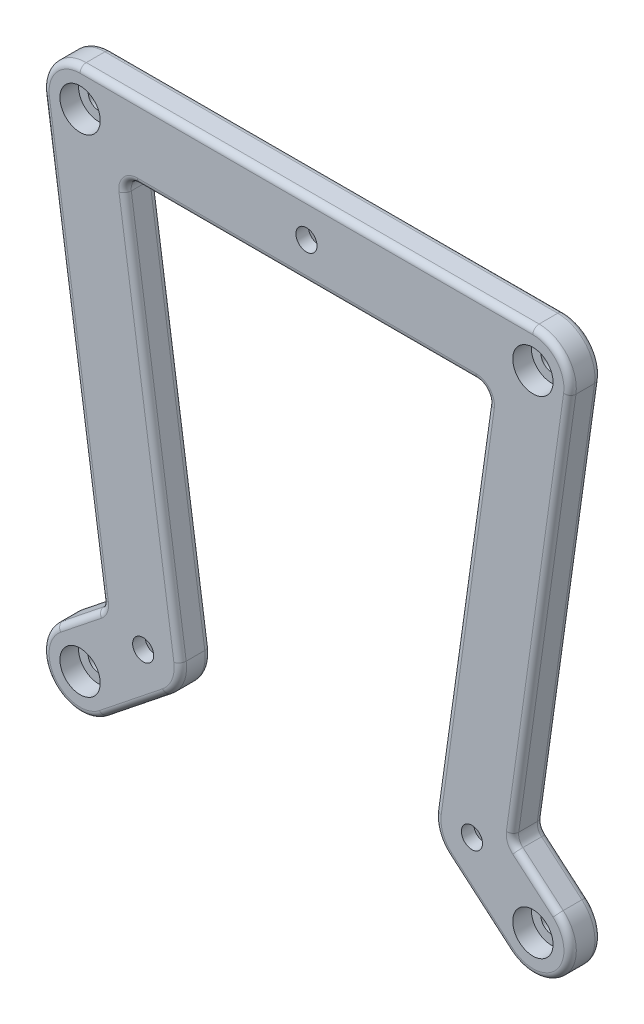
from build123d import *

# Parameters (mm, degrees)
ESQUISSE1_R             = 1.7
BOSS_EXTRU_1_DEPTH      = 5
CONG_1_R                = 2
ESQUISSE2_R             = 3.25
ENL_V_MAT_EXTRU_1_DEPTH = 3
ENL_V_MAT_EXTRU_2_DEPTH = 3
CONG_2_R                = 1


with BuildPart() as part:
    # Esquisse1 → Boss.-Extru.1 (new body)
    with BuildSketch(Plane.XY):
        with BuildLine():
            Line((-22.586329424, -40.018809083), (-32.756329424, -48.138809083))
            ThreePointArc((-32.756329424, -48.138809083), (-41.188809083, -47.193670576), (-40.243670576, -38.761190917))
            Line((-40.243670576, -38.761190917), (-32.759933126, -32.785974782))
            Line((-32.759933126, -32.785974782), (-42.438322378, 34.191904823))
            ThreePointArc((-42.438322378, 34.191904823), (-41.035888615, 38.977558334), (-36.5, 41.05))
            Line((-36.5, 41.05), (36.5, 41.05))
            ThreePointArc((36.5, 41.05), (41.027654088, 38.987048192), (42.441864113, 34.216782821))
            Line((42.441864113, 34.216782821), (33.06867678, -32.625580558))
            Line((33.06867678, -32.625580558), (40.397865204, -38.888569648))
            ThreePointArc((40.397865204, -38.888569648), (41.061430352, -47.347865204), (32.602134796, -48.011430352))
            Line((32.602134796, -48.011430352), (22.772134796, -39.611430352))
            ThreePointArc((22.772134796, -39.611430352), (21.059240359, -37.175882464), (20.728135887, -34.216782821))
            Line((20.728135887, -34.216782821), (29.599925832, 29.05))
            Line((29.599925832, 29.05), (-29.570674099, 29.05))
            Line((-29.570674099, 29.05), (-20.391677622, -34.471904823))
            ThreePointArc((-20.391677622, -34.471904823), (-20.750816941, -37.53742302), (-22.586329424, -40.018809083))
        make_face()
        with Locations((0, 35.05)):
            Circle(ESQUISSE1_R, mode=Mode.SUBTRACT)
        with Locations((-26.33, -35.33)):
            Circle(ESQUISSE1_R, mode=Mode.SUBTRACT)
        with Locations((26.67, -35.05)):
            Circle(ESQUISSE1_R, mode=Mode.SUBTRACT)
        with Locations((-36.5, 35.05)):
            Circle(ESQUISSE1_R, mode=Mode.SUBTRACT)
        with Locations((36.5, 35.05)):
            Circle(ESQUISSE1_R, mode=Mode.SUBTRACT)
        with Locations((-36.5, -43.45)):
            Circle(ESQUISSE1_R, mode=Mode.SUBTRACT)
        with Locations((36.5, -43.45)):
            Circle(ESQUISSE1_R, mode=Mode.SUBTRACT)
    extrude(amount=BOSS_EXTRU_1_DEPTH)

    # Congé1
    cong_1_edges = [part.edges().sort_by_distance(p)[0] for p in [
        (-32.759933126, -32.785974782, 2.5),
        (33.06867678, -32.625580558, 2.5),
        (29.599925832, 29.05, 2.5),
        (-29.570674099, 29.05, 2.5),
    ]]
    fillet(cong_1_edges, radius=CONG_1_R)

    # Esquisse2 → Enlèv. mat.-Extru.1 (cut)
    with BuildSketch(Plane.XY.offset(5)):
        with Locations((-36.5, 35.05)):
            Circle(ESQUISSE2_R)
        with Locations((36.5, 35.05)):
            Circle(ESQUISSE2_R)
        with Locations((36.5, -43.45)):
            Circle(ESQUISSE2_R)
        with Locations((-36.5, -43.45)):
            Circle(ESQUISSE2_R)
    extrude(amount=-ENL_V_MAT_EXTRU_1_DEPTH, mode=Mode.SUBTRACT)

    # Esquisse3 → Enlèv. mat.-Extru.2 (cut)
    with BuildSketch(Plane(origin=(0, 0, 0), x_dir=(-1, 0, 0), z_dir=(0, 0, -1))):
        Polygon((-1.645448267, 37.9), (1.645448267, 37.9), (3.290896534, 35.05), (1.645448267, 32.2), (-1.645448267, 32.2), (-3.290896534, 35.05), align=None)
        Polygon((-28.315448267, -32.2), (-25.024551733, -32.2), (-23.379103466, -35.05), (-25.024551733, -37.9), (-28.315448267, -37.9), (-29.960896534, -35.05), align=None)
        Polygon((24.684551733, -32.48), (27.975448267, -32.48), (29.620896534, -35.33), (27.975448267, -38.18), (24.684551733, -38.18), (23.039103466, -35.33), align=None)
    extrude(amount=-ENL_V_MAT_EXTRU_2_DEPTH, mode=Mode.SUBTRACT)

    # Congé2
    cong_2_edges = [part.edges().sort_by_distance(p)[0] for p in [
        (-27.671329424, -44.078809083, 0),
        (-41.188809083, -47.193670576, 0),
        (-37.681062877, 1.269985086, 0),
        (-41.035888615, 38.977558334, 0),
        (0, 41.05, 0),
        (41.027654088, 38.987048192, 0),
        (37.150072921, -36.113243588, 0),
        (41.061430352, -47.347865204, 0),
        (27.687134796, -43.811430352, 0),
        (21.059240359, -37.175882464, 0),
        (21.059240359, -37.175882464, 5),
        (-24.816008606, -3.853968274, 0),
        (-20.750816941, -37.53742302, 0),
        (27.687134796, -43.811430352, 5),
        (41.061430352, -47.347865204, 5),
        (37.150072921, -36.113243588, 5),
        (41.027654088, 38.987048192, 5),
        (0, 41.05, 5),
        (-41.035888615, 38.977558334, 5),
        (-20.750816941, -37.53742302, 5),
        (-37.681062877, 1.269985086, 5),
        (-41.188809083, -47.193670576, 5),
        (-27.671329424, -44.078809083, 5),
        (0.019501156, 29.05, 0),
        (0.019501156, 29.05, 5),
        (25.004329184, -3.72226094, 0),
        (25.004329184, -3.72226094, 5),
        (37.831405891, 1.338540569, 0),
        (37.831405891, 1.338540569, 5),
        (-36.949512276, -36.131046827, 0),
        (-36.949512276, -36.131046827, 5),
        (-28.77286167, 28.359186111, 0),
        (-28.77286167, 28.359186111, 5),
        (28.809119139, 28.362349397, 0),
        (28.809119139, 28.362349397, 5),
        (33.331315826, -32.526068232, 0),
        (33.331315826, -32.526068232, 5),
        (-33.043516481, -32.673774049, 0),
        (-33.043516481, -32.673774049, 5),
        (-24.816008606, -3.853968274, 5),
    ]]
    fillet(cong_2_edges, radius=CONG_2_R)


solid = part.part
